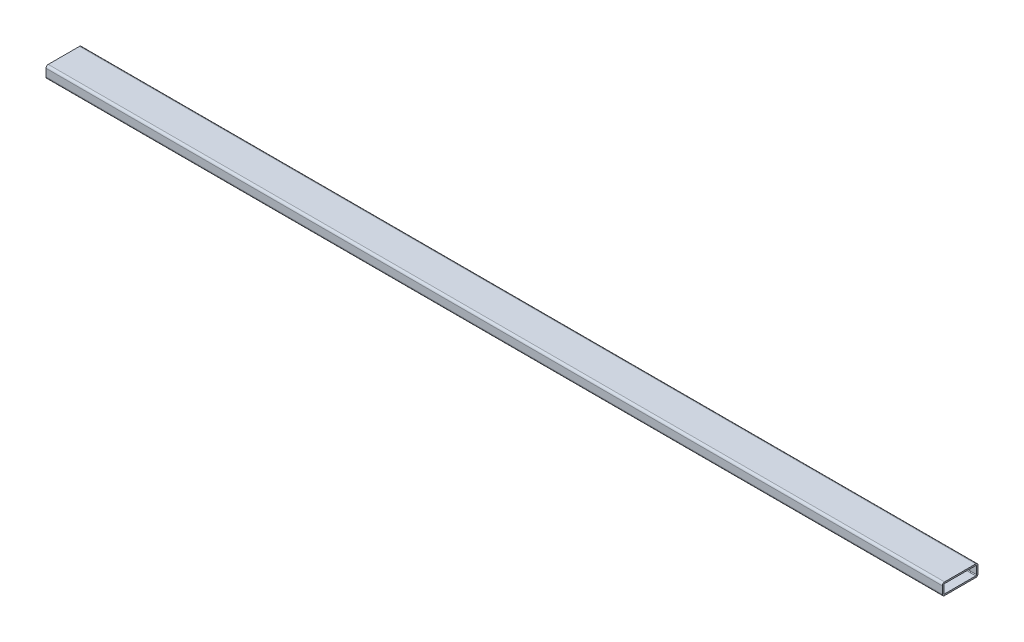
from build123d import *

# Parameters (mm, degrees)
BOSS_EXTRUDE1_DEPTH = 957.2625


with BuildPart() as part:
    # Sketch1 → Boss-Extrude1 (new body, symmetric)
    with BuildSketch(Plane(origin=(0, 0, 0), x_dir=(0, 0, -1), z_dir=(1, 0, 0))):
        with BuildLine():
            Line((33.3248, 25.4), (-33.3248, 25.4))
            ThreePointArc((-33.3248, 25.4), (-36.701376302, 24.001376302), (-38.1, 20.6248))
            Line((-38.1, 20.6248), (-38.1, 4.7752))
            ThreePointArc((-38.1, 4.7752), (-36.701376302, 1.398623698), (-33.3248, 0))
            Line((-33.3248, 0), (33.3248, 0))
            ThreePointArc((33.3248, 0), (36.701376302, 1.398623698), (38.1, 4.7752))
            Line((38.1, 4.7752), (38.1, 20.6248))
            ThreePointArc((38.1, 20.6248), (36.701376302, 24.001376302), (33.3248, 25.4))
        make_face()
        with BuildLine():
            Line((33.3248, 22.225), (-33.3248, 22.225))
            ThreePointArc((-33.3248, 22.225), (-34.456312271, 21.756312271), (-34.925, 20.6248))
            Line((-34.925, 20.6248), (-34.925, 4.7752))
            ThreePointArc((-34.925, 4.7752), (-34.456312271, 3.643687729), (-33.3248, 3.175))
            Line((-33.3248, 3.175), (33.3248, 3.175))
            ThreePointArc((33.3248, 3.175), (34.456312271, 3.643687729), (34.925, 4.7752))
            Line((34.925, 4.7752), (34.925, 20.6248))
            ThreePointArc((34.925, 20.6248), (34.456312271, 21.756312271), (33.3248, 22.225))
        make_face(mode=Mode.SUBTRACT)
    extrude(amount=BOSS_EXTRUDE1_DEPTH, both=True)


solid = part.part
